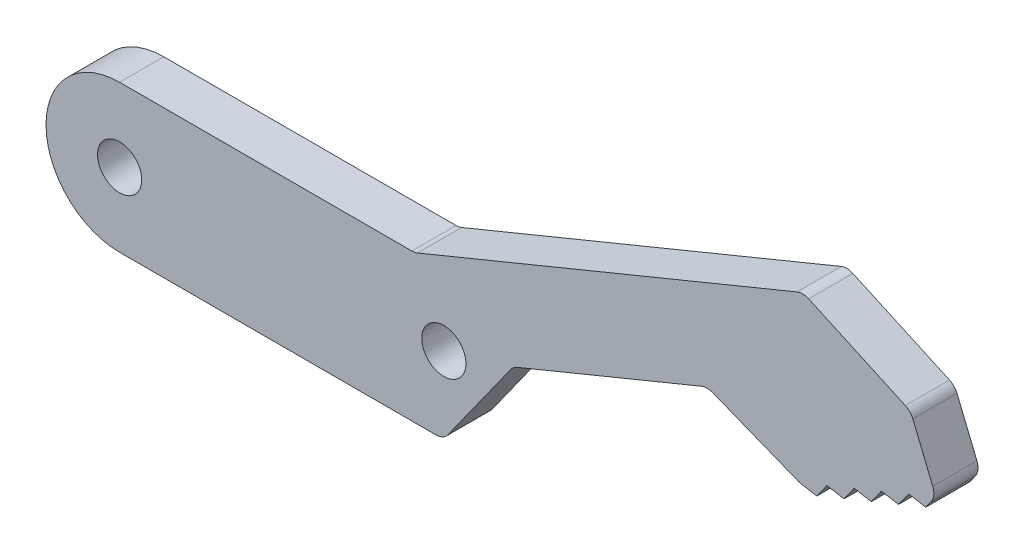
from build123d import *

# Parameters (mm, degrees)
SKETCH1_R           = 1.5
BOSS_EXTRUDE3_DEPTH = 3
FILLET1_R           = 1


with BuildPart() as part:
    # Sketch1 → Boss-Extrude3 (new body)
    with BuildSketch(Plane.XY):
        with BuildLine():
            Line((20.05, 5), (0, 5))
            ThreePointArc((0, 5), (-5, 0), (0, -5))
            Line((0, -5), (22, -5))
            Line((22, -5), (26.72989842, 1.621129525))
            Line((26.72989842, 1.621129525), (39.900164389, 7.036080522))
            Line((39.900164389, 7.036080522), (46.188488025, 4.540007042))
            Line((46.188488025, 4.540007042), (47.352932204, 4.337597171))
            Line((47.352932204, 4.337597171), (48.038244482, 5.300533868))
            Line((48.038244482, 5.300533868), (49.20268866, 5.098123997))
            Line((49.20268866, 5.098123997), (49.888000938, 6.061060693))
            Line((49.888000938, 6.061060693), (51.052445116, 5.858650822))
            Line((51.052445116, 5.858650822), (51.737757394, 6.821587519))
            Line((51.737757394, 6.821587519), (52.902201573, 6.619177648))
            Line((52.902201573, 6.619177648), (53.587513851, 7.582114344))
            Line((53.587513851, 7.582114344), (54.751958029, 7.379704473))
            Line((54.751958029, 7.379704473), (55.437270307, 8.34264117))
            Line((55.437270307, 8.34264117), (53.72608495, 12.504593197))
            Line((53.72608495, 12.504593197), (46.409029503, 15.837507263))
            Line((46.409029503, 15.837507263), (20.05, 5))
        make_face()
        Circle(SKETCH1_R, mode=Mode.SUBTRACT)
        with Locations((22.020705275, 0.206842568)):
            Circle(SKETCH1_R, mode=Mode.SUBTRACT)
    extrude(amount=BOSS_EXTRUDE3_DEPTH)

    # Fillet1
    fillet1_edges = [part.edges().sort_by_distance(p)[0] for p in [
        (22, -5, 1.5),
        (20.05, 5, 1.5),
        (46.409029503, 15.837507263, 1.5),
        (53.72608495, 12.504593197, 1.5),
        (55.437270307, 8.34264117, 1.5),
        (46.188488025, 4.540007042, 1.5),
        (39.900164389, 7.036080522, 1.5),
        (26.72989842, 1.621129525, 1.5),
    ]]
    fillet(fillet1_edges, radius=FILLET1_R)


solid = part.part
